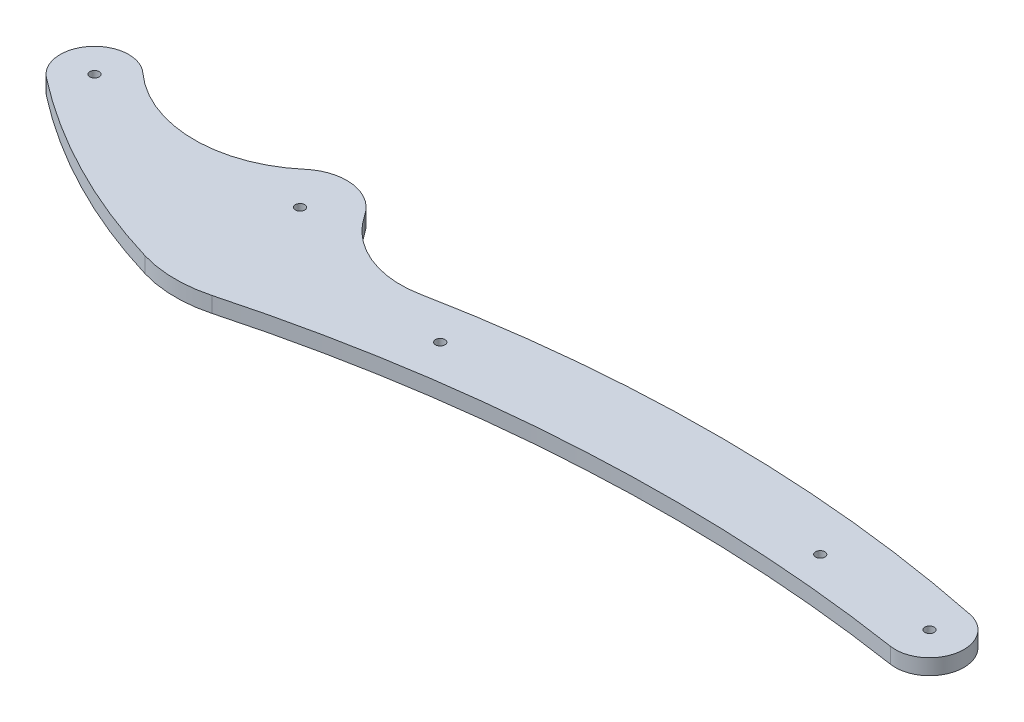
from build123d import *

# Parameters (mm, degrees)
SKETCH1_R           = 1.5
BOSS_EXTRUDE1_DEPTH = 5


with BuildPart() as part:
    # Sketch1 → Boss-Extrude1 (new body)
    with BuildSketch(Plane(origin=(0, 0, 0), x_dir=(1, 0, 0), z_dir=(0, 1, 0))):
        with BuildLine():
            ThreePointArc((30.05067828, -1.98711795), (17.911907525, 1.279041193), (7.386236134, 8.151289209))
            ThreePointArc((7.386236134, 8.151289209), (-8.425357061, 7.07201233), (-6.747627634, -8.68731957))
            ThreePointArc((-6.747627634, -8.68731957), (24.327807705, -28.522008688), (58.515872209, -42.315986336))
            ThreePointArc((58.515872209, -42.315986336), (69.43935161, -43.996070724), (80.405631289, -42.622827932))
            ThreePointArc((80.405631289, -42.622827932), (183.01994094, -26.16258262), (286.820423183, -31.271017511))
            ThreePointArc((286.820423183, -31.271017511), (299.326255976, -22.347352445), (290.71394184, -9.625100394))
            ThreePointArc((290.71394184, -9.625100394), (202.127360194, -0.420820539), (113.463070734, -8.843705436))
            ThreePointArc((113.463070734, -8.843705436), (96.019370903, -7.044766711), (82.561456398, 4.198159132))
            ThreePointArc((82.561456398, 4.198159132), (72.12928734, 10.848102082), (60.248711806, 7.397911149))
            ThreePointArc((60.248711806, 7.397911149), (46.116503766, -0.405485841), (30.05067828, -1.98711795))
        make_face()
        with Locations((130, -19)):
            Circle(SKETCH1_R, mode=Mode.SUBTRACT)
        with Locations((250, -17)):
            Circle(SKETCH1_R, mode=Mode.SUBTRACT)
        with Locations((288.5, -20.4)):
            Circle(SKETCH1_R, mode=Mode.SUBTRACT)
        with Locations((70, -4)):
            Circle(SKETCH1_R, mode=Mode.SUBTRACT)
        Circle(SKETCH1_R, mode=Mode.SUBTRACT)
    extrude(amount=BOSS_EXTRUDE1_DEPTH)


solid = part.part
